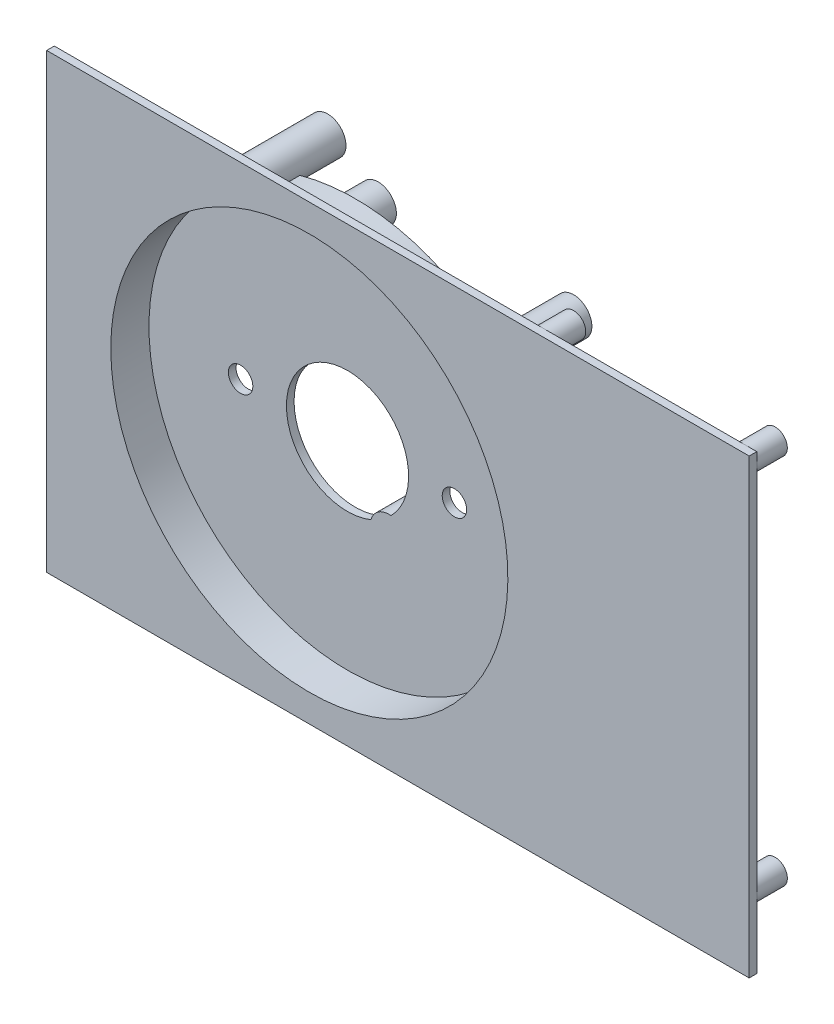
from build123d import *

# Parameters (mm, degrees)
SKETCH1_W                       = 146.05
SKETCH1_H                       = 93.98
SKETCH1_R                       = 41.275
MAIN_DEPTH                      = 1.5875
SKETCH2_R                       = 41.275
SKETCH2_R_2                     = 2.54
SKETCH2_R_3                     = 12.7
DISK_TOP_DEPTH                  = 1.5875
RAISED_START                    = -7.9375
SKETCH3_R                       = 42.8625
SKETCH3_R_2                     = 41.275
RAISED_DISK_DEPTH               = 7.9375
SKETCH4_R                       = 3.81
SKETCH4_R_2                     = 1.2239625
SS_RELAY_MOUNTING_POSTS_DEPTH   = 17.4625
SKETCH5_R                       = 2.54
SKETCH5_R_2                     = 1.190625
MECH_RELAY_MOUNTING_POSTS_DEPTH = 6.35
SKETCH6_R                       = 3.81
SKETCH6_R_2                     = 1.190625
ARDUINO_MOUNTING_1_DEPTH        = 7.9375
SKETCH7_R                       = 3.81
ARDUINO_MOUNTING_2_DEPTH        = 6.35


with BuildPart() as part:
    # Sketch1 → main (new body)
    with BuildSketch(Plane(origin=(0, 0, 7.9375), x_dir=(-1, 0, 0), z_dir=(0, 0, -1))):
        with Locations((-18.415, 0)):
            Rectangle(SKETCH1_W, SKETCH1_H)
        Circle(SKETCH1_R, mode=Mode.SUBTRACT)
    extrude(amount=MAIN_DEPTH)



with BuildPart() as body_2:
    # Sketch2 → disk top (new body)
    with BuildSketch(Plane(origin=(0, 0, 0), x_dir=(-1, 0, 0), z_dir=(0, 0, -1))):
        Circle(SKETCH2_R)
        with Locations((22.225, 0)):
            Circle(SKETCH2_R_2, mode=Mode.SUBTRACT)
        with Locations((-22.225, 0)):
            Circle(SKETCH2_R_2, mode=Mode.SUBTRACT)
        Circle(SKETCH2_R_3, mode=Mode.SUBTRACT)
    extrude(amount=DISK_TOP_DEPTH)


with BuildPart() as part_1:
    add(part.part)

    add(body_2.part)  # raised disk merges body 2
    # Sketch3 → raised disk (add)
    with BuildSketch(Plane(origin=(0, 0, -1.5875), x_dir=(-1, 0, 0), z_dir=(0, 0, -1)).offset(RAISED_START)):
        Circle(SKETCH3_R)
        Circle(SKETCH3_R_2, mode=Mode.SUBTRACT)
    extrude(amount=RAISED_DISK_DEPTH)

    # Sketch4 → SS relay mounting posts (add)
    with BuildSketch(Plane(origin=(0, 0, 6.35), x_dir=(-1, 0, 0), z_dir=(0, 0, -1))):
        with Locations((15.24, 41.91)):
            Circle(SKETCH4_R)
        with Locations((15.24, 41.91)):
            Circle(SKETCH4_R_2, mode=Mode.SUBTRACT)
        with Locations((15.24, -44.45)):
            Circle(SKETCH4_R)
        with Locations((15.24, -44.45)):
            Circle(SKETCH4_R_2, mode=Mode.SUBTRACT)
    extrude(amount=SS_RELAY_MOUNTING_POSTS_DEPTH)

    # Sketch5 → mech relay mounting posts (add)
    with BuildSketch(Plane(origin=(0, 0, 6.35), x_dir=(-1, 0, 0), z_dir=(0, 0, -1))):
        with Locations((-46.99, 44.45)):
            Circle(SKETCH5_R)
        with Locations((-46.99, 44.45)):
            Circle(SKETCH5_R_2, mode=Mode.SUBTRACT)
        with Locations((-88.9, 44.45)):
            Circle(SKETCH5_R)
        with Locations((-88.9, 44.45)):
            Circle(SKETCH5_R_2, mode=Mode.SUBTRACT)
        with Locations((-46.99, 24.13)):
            Circle(SKETCH5_R)
        with Locations((-46.99, 24.13)):
            Circle(SKETCH5_R_2, mode=Mode.SUBTRACT)
        with Locations((-46.99, -33.02)):
            Circle(SKETCH5_R)
        with Locations((-46.99, -33.02)):
            Circle(SKETCH5_R_2, mode=Mode.SUBTRACT)
        with Locations((-88.9, -33.02)):
            Circle(SKETCH5_R)
        with Locations((-88.9, -33.02)):
            Circle(SKETCH5_R_2, mode=Mode.SUBTRACT)
    extrude(amount=MECH_RELAY_MOUNTING_POSTS_DEPTH)

    # Sketch6 → Arduino mounting 1 (add)
    with BuildSketch(Plane.XY.offset(-7.9375)):
        with Locations((39.0525, 38.1)):
            Circle(SKETCH6_R)
        with Locations((39.0525, 38.1)):
            Circle(SKETCH6_R_2, mode=Mode.SUBTRACT)
        with Locations((-1.5875, 38.1)):
            Circle(SKETCH6_R)
        with Locations((-1.5875, 38.1)):
            Circle(SKETCH6_R_2, mode=Mode.SUBTRACT)
        with Locations((8.5725, -12.7)):
            Circle(SKETCH6_R)
        with Locations((8.5725, -12.7)):
            Circle(SKETCH6_R_2, mode=Mode.SUBTRACT)
        with Locations((39.0525, -12.7)):
            Circle(SKETCH6_R)
        with Locations((39.0525, -12.7)):
            Circle(SKETCH6_R_2, mode=Mode.SUBTRACT)
    extrude(amount=ARDUINO_MOUNTING_1_DEPTH)

    # Sketch7 → Arduino mounting 2 (add)
    with BuildSketch(Plane(origin=(0, 0, 6.35), x_dir=(-1, 0, 0), z_dir=(0, 0, -1))):
        with Locations((-39.0525, 38.1)):
            Circle(SKETCH7_R)
        with BuildLine():
            Line((-39.569913642, -16.474703051), (-41.691221214, -9.951682268))
            ThreePointArc((-41.691221214, -9.951682268), (-42.675723267, -13.878283989), (-39.569913642, -16.474703051))
        make_face()
    extrude(amount=ARDUINO_MOUNTING_2_DEPTH)


solid = part_1.part
